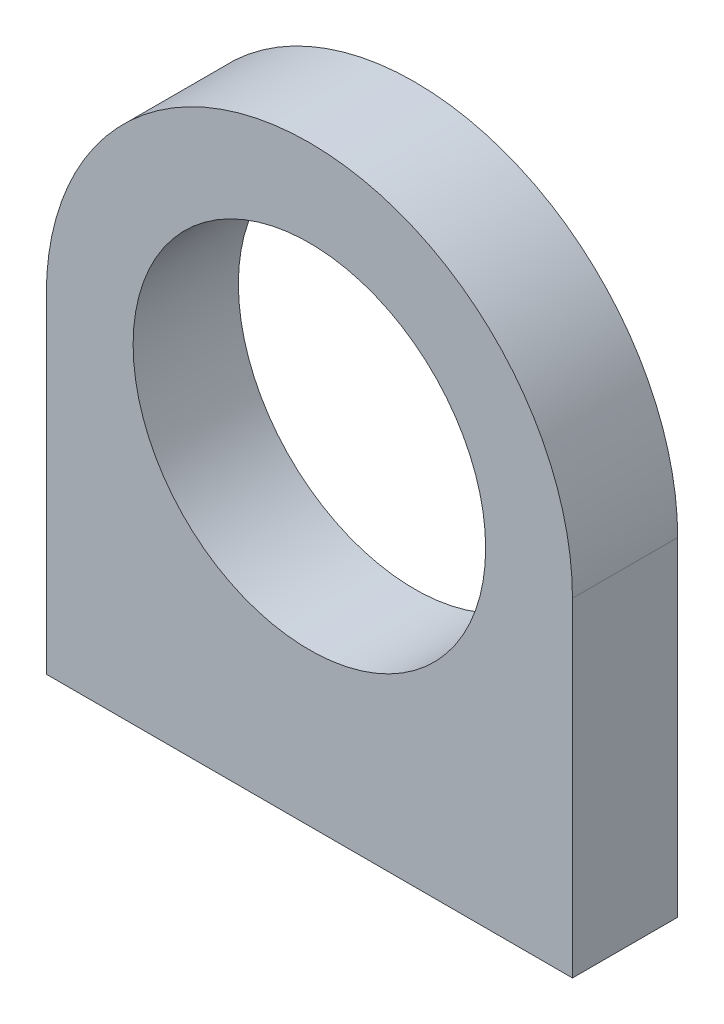
from build123d import *

# Parameters (mm, degrees)
ESQUISSE1_R             = 7
ESQUISSE1_R_2           = 1.8
BOSS_EXTRU_1_DEPTH      = 8
ESQUISSE2_R             = 13.4
ENL_V_MAT_EXTRU_1_DEPTH = 9
ESQUISSE3_R             = 2
ENL_V_MAT_EXTRU_2_DEPTH = 12
CHANFREIN1_SIZE         = 1


with BuildPart() as part:
    # Esquisse1 → Boss.-Extru.1 (new body)
    with BuildSketch(Plane.XY):
        with BuildLine():
            Line((-20, 0), (-20, -25))
            Line((-20, -25), (20, -25))
            Line((20, -25), (20, 0))
            ThreePointArc((20, 0), (0, 20), (-20, 0))
        make_face()
        Circle(ESQUISSE1_R, mode=Mode.SUBTRACT)
        with Locations((0, 10)):
            Circle(ESQUISSE1_R_2, mode=Mode.SUBTRACT)
        with Locations((10, 0)):
            Circle(ESQUISSE1_R_2, mode=Mode.SUBTRACT)
        with Locations((0, -10)):
            Circle(ESQUISSE1_R_2, mode=Mode.SUBTRACT)
        with Locations((-10, 0)):
            Circle(ESQUISSE1_R_2, mode=Mode.SUBTRACT)
    extrude(amount=BOSS_EXTRU_1_DEPTH)

    # Esquisse2 → Enlèv. mat.-Extru.1 (cut, through all)
    with BuildSketch(Plane.XY.offset(8)):
        Circle(ESQUISSE2_R)
    extrude(amount=-ENL_V_MAT_EXTRU_1_DEPTH, mode=Mode.SUBTRACT)

    # Esquisse3 → Enlèv. mat.-Extru.2 (cut)
    with BuildSketch(Plane.XZ.offset(25)):
        with Locations((-15, 4)):
            Circle(ESQUISSE3_R)
        with Locations((15, 4)):
            Circle(ESQUISSE3_R)
    extrude(amount=-ENL_V_MAT_EXTRU_2_DEPTH, mode=Mode.SUBTRACT)

    # Chanfrein1
    chanfrein1_edges = [part.edges().sort_by_distance(p)[0] for p in [
        (-17, -25, 4),
        (13, -25, 4),
    ]]
    chamfer(chanfrein1_edges, length=CHANFREIN1_SIZE)


solid = part.part
